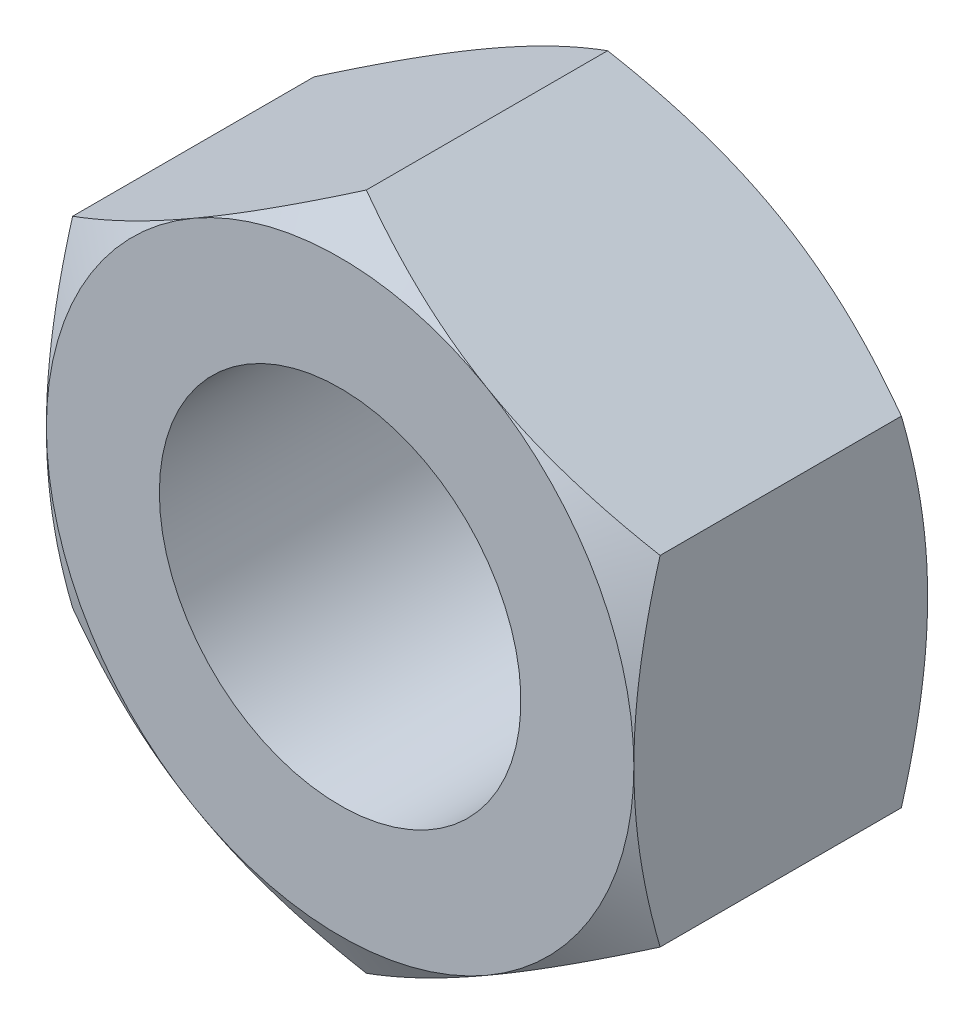
from build123d import *

# Parameters (mm, degrees)
EXTRUDE1_DEPTH          = 3.25
SKETCH13_R              = 4
BOSS_EXTRUDE1_DEPTH     = 6.5
SKETCH7_OUTSIDE_W       = 107.168
SKETCH7_OUTSIDE_H       = 109.18
SKETCH7_OUTSIDE_R       = 6.5
EXTRUDE2_DEPTH          = 25.4
EXTRUDE2_DRAFT          = -60
MIRROR2_COPY_1_SKETCH_W = 107.168
MIRROR2_COPY_1_SKETCH_H = 109.18
MIRROR2_COPY_1_SKETCH_R = 6.5
MIRROR2_COPY_1_DEPTH    = 25.4
MIRROR2_COPY_1_DRAFT    = -60


with BuildPart() as part:
    # Sketch1 → Extrude1 (new, symmetric)
    with BuildSketch(Plane.XY):
        Polygon((-6.5, 3.75277675), (-6.5, -3.75277675), (0, -7.505553499), (6.5, -3.75277675), (6.5, 3.75277675), (0, 7.505553499), align=None)
    extrude(amount=EXTRUDE1_DEPTH, both=True)

    # Cut-Extrude2 cone 1 section (through the dimple's axis) → Cut-Extrude2 (revolve, cut)
    with BuildSketch(Plane(origin=(0, 0, 3.25), x_dir=(0, -1, 0), z_dir=(1, 0, 0))):
        Polygon((0, 0), (4, 0), (0, 4), align=None)
    revolve(axis=Axis((0, 0, 3.25), (0, 0, -1)), mode=Mode.SUBTRACT)

    # Cut-Extrude3 cone 1 section (through the dimple's axis) → Cut-Extrude3 (revolve, cut)
    with BuildSketch(Plane(origin=(0, 0, -3.25), x_dir=(0, 1, 0), z_dir=(1, 0, 0))):
        Polygon((0, 0), (4, 0), (0, 4), align=None)
    revolve(axis=Axis((0, 0, -3.25), (0, 0, 1)), mode=Mode.SUBTRACT)


with BuildPart() as body_2:
    # Sketch13 → Boss-Extrude1 (new body)
    with BuildSketch(Plane(origin=(0, 0, -3.25), x_dir=(-1, 0, 0), z_dir=(0, 0, -1))):
        Circle(SKETCH13_R)
    extrude(amount=-BOSS_EXTRUDE1_DEPTH)


with BuildPart() as part_1:
    add(part.part)

    # Combine1: cut body 2
    add(body_2.part, mode=Mode.SUBTRACT)


with BuildPart() as extrude2_tool:
    # Sketch7 outside → Extrude2 (with draft: the straight prism first)
    with BuildSketch(Plane.XY.offset(3.25)):
        Rectangle(SKETCH7_OUTSIDE_W, SKETCH7_OUTSIDE_H)
        Circle(SKETCH7_OUTSIDE_R, mode=Mode.SUBTRACT)
    extrude(amount=-EXTRUDE2_DEPTH)
    # Extrude2: the draft: its side faces are tilted about the plane it starts from
    extrude2_sides = [extrude2_tool.faces().sort_by_distance(p)[0] for p in [
        (0, -54.59, -9.45),
        (53.584, 0, -9.45),
        (0, 54.59, -9.45),
        (-53.584, 0, -9.45),
        (-6.5, 0, -9.45),
    ]]
    draft(extrude2_sides, Plane.XY.offset(3.25), EXTRUDE2_DRAFT)


with BuildPart() as part_2:
    add(part_1.part)

    # Extrude2: cut by extrude2_tool
    add(extrude2_tool.part, mode=Mode.SUBTRACT)


with BuildPart() as mirror2_copy_1_tool:
    # Mirror2 copy 1 sketch → Mirror2 copy 1 (with draft: the straight prism first)
    with BuildSketch(Plane(origin=(0, 0, -3.25), x_dir=(1, 0, 0), z_dir=(0, 0, -1))):
        Rectangle(MIRROR2_COPY_1_SKETCH_W, MIRROR2_COPY_1_SKETCH_H)
        Circle(MIRROR2_COPY_1_SKETCH_R, mode=Mode.SUBTRACT)
    extrude(amount=-MIRROR2_COPY_1_DEPTH)
    # Mirror2 copy 1: the draft: its side faces are tilted about the plane it starts from
    mirror2_copy_1_sides = [mirror2_copy_1_tool.faces().sort_by_distance(p)[0] for p in [
        (0, -54.59, 9.45),
        (53.584, 0, 9.45),
        (0, 54.59, 9.45),
        (-53.584, 0, 9.45),
        (-6.5, 0, 9.45),
    ]]
    draft(mirror2_copy_1_sides, Plane(origin=(0, 0, -3.25), x_dir=(1, 0, 0), z_dir=(0, 0, -1)), MIRROR2_COPY_1_DRAFT)


with BuildPart() as part_3:
    add(part_2.part)

    # Mirror2 copy 1: cut by mirror2_copy_1_tool
    add(mirror2_copy_1_tool.part, mode=Mode.SUBTRACT)


solid = part_3.part
